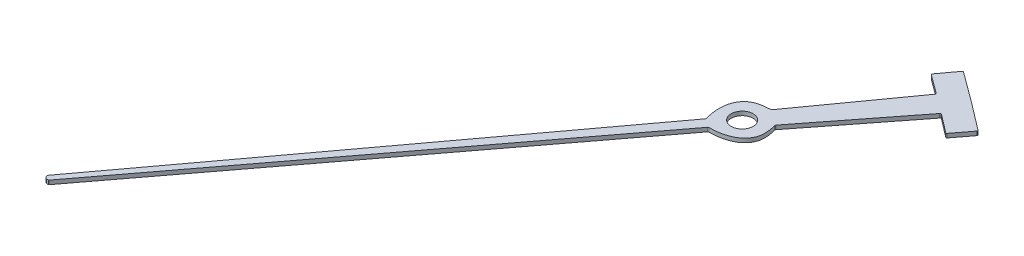
from build123d import *

# Parameters (mm, degrees)
BOSS_EXTRUDE1_DEPTH = 2
FILLET2_R           = 0.5
SKETCH2_R           = 5.5
CUT_EXTRUDE1_DEPTH  = 3.0000001
SCALE1_SCALE        = 0.05848


with BuildPart() as part:
    # Sketch1 → Boss-Extrude1 (new body)
    with BuildSketch(Plane(origin=(0, 0, 0), x_dir=(1, 0, 0), z_dir=(0, 1, 0))):
        with BuildLine():
            Line((92.085110733, 127.103938413), (77.178124527, 138.062250462))
            Line((77.178124527, 138.062250462), (70.360301054, 128.787719859))
            Line((70.360301054, 128.787719859), (80.370912811, 121.428793922))
            Line((80.370912811, 121.428793922), (45.876712151, 73.307436464))
            add(Edge.make_bspline(
                [(33.451049577, 53.126345945), (31.215883749, 60.494948343), (32.447141404, 70.446648696), (40.862115825, 73.16760251), (45.876712151, 73.307436464)],
                knots=[0, 0, 0, 0, 0.641849019, 1, 1, 1, 1], degree=3))
            Line((33.451049577, 53.126345945), (-106.799876202, -136.181201423))
            ThreePointArc((-106.799876202, -136.181201423), (-106.088492795, -137.707043736), (-104.423962902, -137.959236822))
            Line((-104.423962902, -137.959236822), (37.646178322, 49.986884833))
            add(Edge.make_bspline(
                [(37.646178322, 49.986884833), (45.3460396, 49.920523216), (54.546555656, 53.908359677), (54.783891194, 62.749120731), (53.503843784, 67.599606116)],
                knots=[0, 0, 0, 0, 0.641849019, 1, 1, 1, 1], degree=3))
            Line((53.503843784, 67.599606116), (89.943937285, 114.264737729))
            Line((89.943937285, 114.264737729), (99.827328979, 106.735813017))
            Line((99.827328979, 106.735813017), (106.802651201, 115.89247806))
            Line((106.802651201, 115.89247806), (92.085110733, 127.103938413))
        make_face()
    extrude(amount=BOSS_EXTRUDE1_DEPTH)

    # Fillet2
    fillet2_edges = [part.edges().sort_by_distance(p)[0] for p in [
        (-104.423962902, 1, 137.959236822),
        (-106.799876202, 1, 136.181201423),
        (33.451049577, 1, -53.126345945),
        (37.646178322, 1, -49.986884833),
        (45.876712151, 1, -73.307436464),
        (53.503843784, 1, -67.599606116),
        (99.827328979, 1, -106.735813017),
        (89.943937285, 1, -114.264737729),
        (80.370912811, 1, -121.428793922),
        (70.360301054, 1, -128.787719859),
        (77.178124527, 1, -138.062250462),
        (106.802651201, 1, -115.89247806),
    ]]
    fillet(fillet2_edges, radius=FILLET2_R)

    # Sketch2 → Cut-Extrude1 (cut, through all)
    with BuildSketch(Plane(origin=(0, 2, 0), x_dir=(1, 0, 0), z_dir=(0, 1, 0))):
        with Locations((43.025259326, 61.547339532)):
            Circle(SKETCH2_R)
    extrude(amount=-CUT_EXTRUDE1_DEPTH, mode=Mode.SUBTRACT)


with BuildPart() as part_1:
    # Scale1: scaled about (28.469603302, 1, -42.097394776)
    add(part.part.scale(SCALE1_SCALE).moved(Location((26.804700901, 0.94152, -39.635539129))))


solid = part_1.part
